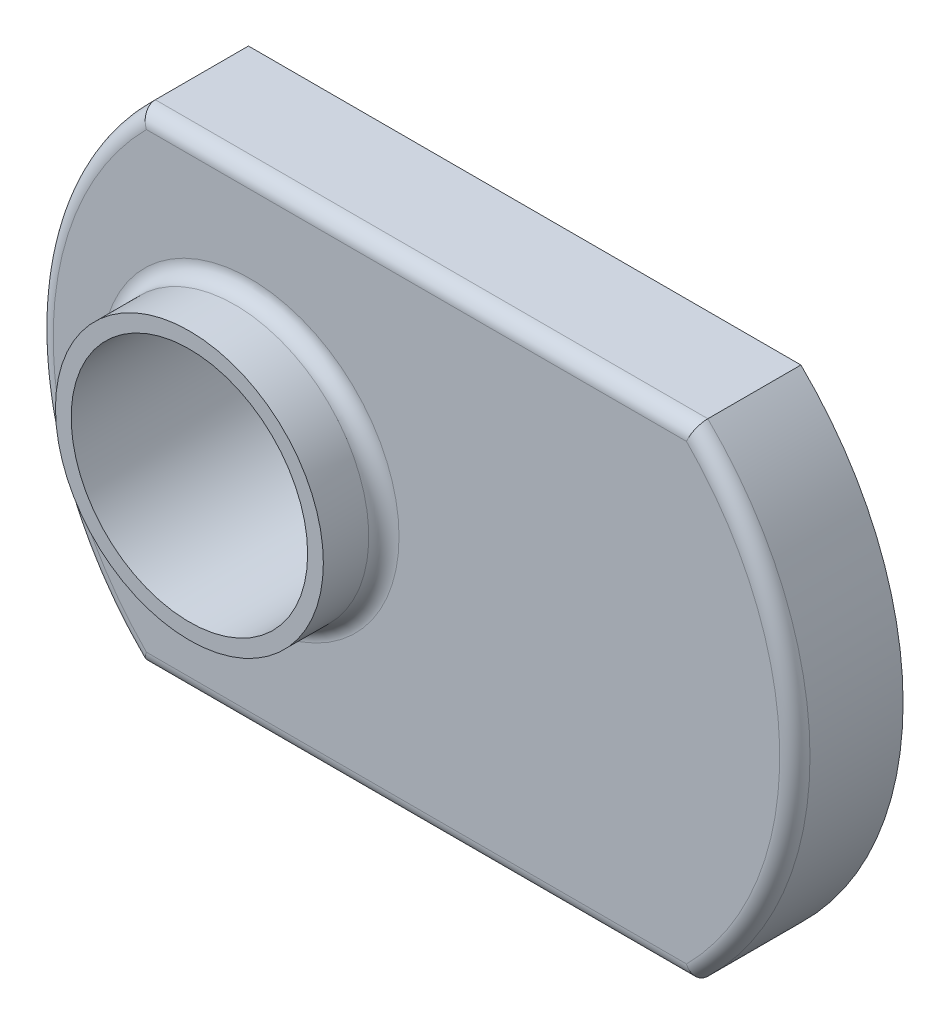
from build123d import *

# Parameters (mm, degrees)
SKETCH1_W                          = 25.4
SKETCH1_H                          = 16.2052
BASE_EXTRUDE_DEPTH                 = 3.6322
SKETCH2_R                          = 4.4958
BOSS_EXTRUDE1_DEPTH                = 2.032
F_5_16_18_TAPPED_HOLE1_D           = 6.5278
F_5_16_18_TAPPED_HOLE1_CBORE_D     = 7.9375
F_5_16_18_TAPPED_HOLE1_CBORE_DEPTH = 15.875
CUT_EXTRUDE1_DEPTH                 = 3.032
CUT_EXTRUDE1_DEPTH_BACK            = 4.6322
CUT_EXTRUDE2_DEPTH                 = 3.032
CUT_EXTRUDE2_DEPTH_BACK            = 4.6322
FILLET1_R                          = 0.508


with BuildPart() as part:
    # Sketch1 → Base-Extrude (new body)
    with BuildSketch(Plane.XY):
        with Locations((12.7, 8.1026)):
            Rectangle(SKETCH1_W, SKETCH1_H)
    extrude(amount=-BASE_EXTRUDE_DEPTH)

    # Sketch2 → Boss-Extrude1 (add)
    with BuildSketch(Plane.XY):
        with Locations((7.112, 8.1026)):
            Circle(SKETCH2_R)
    extrude(amount=BOSS_EXTRUDE1_DEPTH)

    # 5/16-18 Tapped Hole1 (through all)
    with Locations(Plane(origin=(7.112, 8.1026, 2.032), x_dir=(1, 0, 0), z_dir=(0, 0, 1))):
        with Locations((0, 0)):
            CounterBoreHole(F_5_16_18_TAPPED_HOLE1_D / 2, F_5_16_18_TAPPED_HOLE1_CBORE_D / 2, F_5_16_18_TAPPED_HOLE1_CBORE_DEPTH)

    # Sketch4 → Cut-Extrude1 (cut, two sides)
    with BuildSketch(Plane.XY) as cut_extrude1_sk:
        with BuildLine():
            Line((-24.402199862, 61.181765932), (21.971, 16.2052))
            ThreePointArc((21.971, 16.2052), (25.4, 8.1026), (21.971, 0))
            Line((21.971, 0), (-24.402199862, -44.976565932))
            Line((-24.402199862, -44.976565932), (104.800975772, -44.976565932))
            Line((104.800975772, -44.976565932), (104.800975772, 61.181765932))
            Line((104.800975772, 61.181765932), (-24.402199862, 61.181765932))
        make_face()
    extrude(amount=CUT_EXTRUDE1_DEPTH, mode=Mode.SUBTRACT)
    extrude(cut_extrude1_sk.sketch, amount=-CUT_EXTRUDE1_DEPTH_BACK, mode=Mode.SUBTRACT)

    # Sketch6 → Cut-Extrude2 (cut, two sides)
    with BuildSketch(Plane.XY) as cut_extrude2_sk:
        with BuildLine():
            Line((49.802199862, 61.181765932), (3.429, 16.2052))
            ThreePointArc((3.429, 16.2052), (0, 8.1026), (3.429, 0))
            Line((3.429, 0), (49.802199862, -44.976565932))
            Line((49.802199862, -44.976565932), (-79.400975772, -44.976565932))
            Line((-79.400975772, -44.976565932), (-79.400975772, 61.181765932))
            Line((-79.400975772, 61.181765932), (49.802199862, 61.181765932))
        make_face()
    extrude(amount=CUT_EXTRUDE2_DEPTH, mode=Mode.SUBTRACT)
    extrude(cut_extrude2_sk.sketch, amount=-CUT_EXTRUDE2_DEPTH_BACK, mode=Mode.SUBTRACT)

    # Fillet1
    fillet1_edges = [part.edges().sort_by_distance(p)[0] for p in [
        (12.7, 0, 0),
        (0, 8.1026, 0),
        (12.7, 16.2052, 0),
        (2.6162, 8.1026, 0),
        (25.4, 8.1026, 0),
    ]]
    fillet(fillet1_edges, radius=FILLET1_R)


solid = part.part
